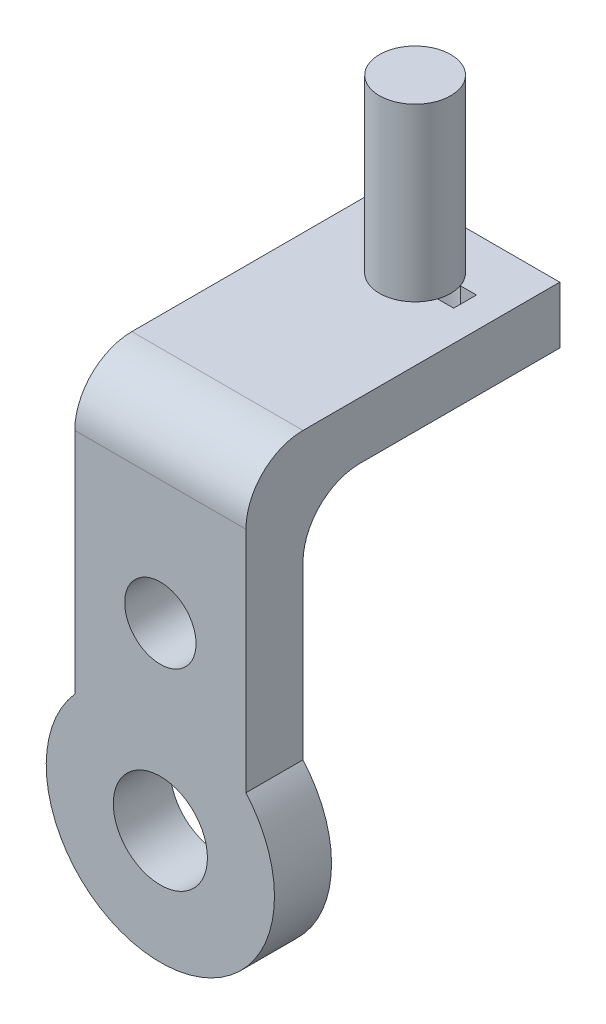
from build123d import *

# Parameters (mm, degrees)
SKETCH1_R           = 16.5
BOSS_EXTRUDE1_DEPTH = 20
SKETCH2_W           = 60
SKETCH2_H           = 20
BOSS_EXTRUDE3_DEPTH = 90
FILLET2_R           = 20
FILLET3_R           = 20
CUT_EXTRUDE1_DEPTH  = 167.5
SKETCH4_R           = 12.5
CUT_EXTRUDE4_DEPTH  = 25
SKETCH5_R           = 12.5
BOSS_EXTRUDE4_DEPTH = 60


with BuildPart() as part:
    # Sketch1 → Boss-Extrude1 (new body)
    with BuildSketch(Plane.XY):
        with BuildLine():
            Line((33.229803266, -31.98019802), (33.267326733, -31.98019802))
            Line((33.267326733, -31.98019802), (33.267326733, 68.01980198))
            Line((33.267326733, 68.01980198), (-26.732673267, 68.01980198))
            Line((-26.732673267, 68.01980198), (-26.732673267, -31.98019802))
            Line((-26.732673267, -31.98019802), (-26.6951498, -31.98019802))
            ThreePointArc((-26.6951498, -31.98019802), (3.267326733, -98.48019802), (33.229803266, -31.98019802))
        make_face()
        with Locations((3.267326733, -58.48019802)):
            Circle(SKETCH1_R, mode=Mode.SUBTRACT)
    extrude(amount=BOSS_EXTRUDE1_DEPTH)

    # Sketch2 → Boss-Extrude3 (add)
    with BuildSketch(Plane(origin=(0, 0, 0), x_dir=(-1, 0, 0), z_dir=(0, 0, -1))):
        with Locations((-3.267326733, 58.01980198)):
            Rectangle(SKETCH2_W, SKETCH2_H)
    extrude(amount=BOSS_EXTRUDE3_DEPTH)

    # Fillet2
    fillet2_edges = [part.edges().sort_by_distance(p)[0] for p in [
        (3.267326733, 68.01980198, 20),
    ]]
    fillet(fillet2_edges, radius=FILLET2_R)

    # Fillet3
    fillet3_edges = [part.edges().sort_by_distance(p)[0] for p in [
        (3.267326733, 48.01980198, 0),
    ]]
    fillet(fillet3_edges, radius=FILLET3_R)

    # Sketch3 → Cut-Extrude1 (cut, through all)
    with BuildSketch(Plane(origin=(0, 68.01980198, 0), x_dir=(1, 0, 0), z_dir=(0, 1, 0))):
        with BuildLine():
            Line((16.903269484, 71.5), (22.560550202, 71.5))
            Line((22.560550202, 71.5), (22.560550202, 63.5))
            Line((22.560550202, 63.5), (16.903269484, 63.5))
            ThreePointArc((16.903269484, 63.5), (-7.439449798, 67.5), (16.903269484, 71.5))
        make_face()
    extrude(amount=-CUT_EXTRUDE1_DEPTH, mode=Mode.SUBTRACT)

    # Sketch4 → Cut-Extrude4 (cut)
    with BuildSketch(Plane.XY.offset(20)):
        with Locations((3.267326733, 4.51980198)):
            Circle(SKETCH4_R)
    extrude(amount=-CUT_EXTRUDE4_DEPTH, mode=Mode.SUBTRACT)


with BuildPart() as body_2:
    # Sketch5 → Boss-Extrude4 (new body)
    with BuildSketch(Plane(origin=(0, 68.01980198, 0), x_dir=(1, 0, 0), z_dir=(0, 1, 0))):
        with Locations((5.060550202, 67.5)):
            Circle(SKETCH5_R)
    extrude(amount=BOSS_EXTRUDE4_DEPTH)


solid = Compound([part.part, body_2.part])
